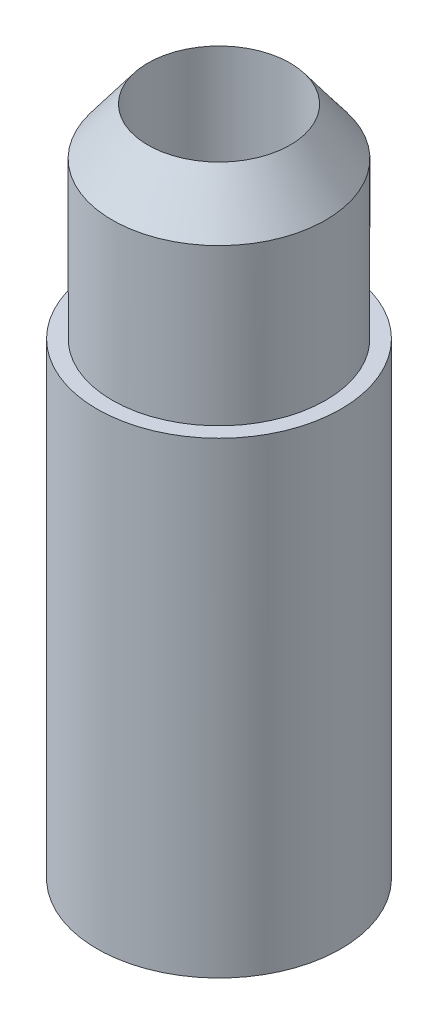
from build123d import *

# Parameters (mm, degrees)
SKETCH1_R           = 19.05
SKETCH1_R_2         = 11.1125
BOSS_EXTRUDE1_DEPTH = 76.2
SKETCH2_R           = 16.66875
SKETCH2_R_2         = 11.1125
BOSS_EXTRUDE2_DEPTH = 31.75


with BuildPart() as part:
    # Sketch1 → Boss-Extrude1 (new body)
    with BuildSketch(Plane(origin=(0, 0, 0), x_dir=(1, 0, 0), z_dir=(0, 1, 0))):
        Circle(SKETCH1_R)
        Circle(SKETCH1_R_2, mode=Mode.SUBTRACT)
    extrude(amount=BOSS_EXTRUDE1_DEPTH)

    # Sketch2 → Boss-Extrude2 (add)
    with BuildSketch(Plane(origin=(0, 76.2, 0), x_dir=(1, 0, 0), z_dir=(0, 1, 0))):
        Circle(SKETCH2_R)
        Circle(SKETCH2_R_2, mode=Mode.SUBTRACT)
    extrude(amount=BOSS_EXTRUDE2_DEPTH)

    # Sketch3 → Cut-Revolve1 (revolve, cut)
    with BuildSketch(Plane(origin=(0, 0, 0), x_dir=(0, 0, -1), z_dir=(1, 0, 0))):
        Polygon((16.66875, 107.95), (16.66875, 100.57660721), (11.1125, 107.95), align=None)
    revolve(axis=Axis((0, 107.95, 0), (0, 1, 0)), mode=Mode.SUBTRACT)

    # Sketch8 → Cut-Revolve4 (revolve, cut)
    with BuildSketch(Plane.XY):
        with BuildLine():
            Line((0, 0), (-3.369464108, 0))
            ThreePointArc((-3.369464108, 0), (-11.368836441, 0.801722978), (-19.05, 3.175))
            Line((-19.05, 3.175), (-19.05, -4.469484217))
            Line((-19.05, -4.469484217), (0, -4.469484217))
            Line((0, -4.469484217), (0, 0))
        make_face()
    revolve(axis=Axis((0, 0, 0), (0, 1, 0)), mode=Mode.SUBTRACT)


solid = part.part
